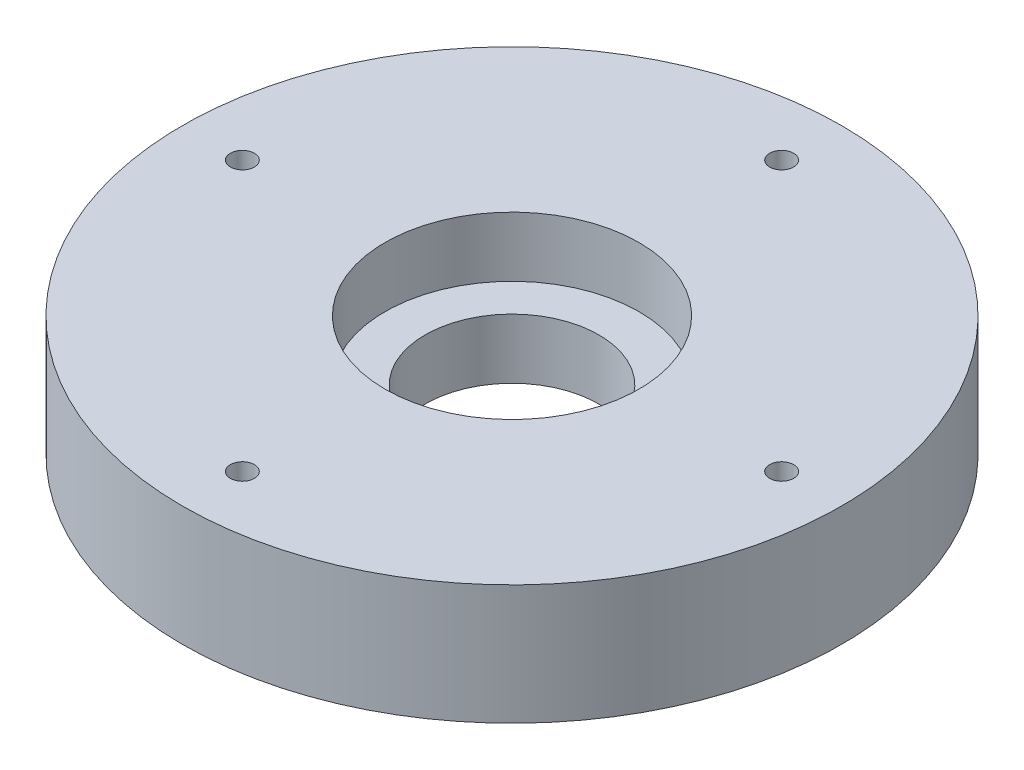
from build123d import *

# Parameters (mm, degrees)
SKETCH1_R           = 55
SKETCH1_R_2         = 14.5
BOSS_EXTRUDE1_DEPTH = 20
SKETCH2_R           = 21.2
CUT_EXTRUDE1_DEPTH  = 10
SKETCH4_R           = 2
CUT_EXTRUDE2_DEPTH  = 20
SKETCH6_R           = 5
CUT_EXTRUDE3_DEPTH  = 5


with BuildPart() as part:
    # Sketch1 → Boss-Extrude1 (new body)
    with BuildSketch(Plane(origin=(0, 0, 0), x_dir=(1, 0, 0), z_dir=(0, 1, 0))):
        Circle(SKETCH1_R)
        Circle(SKETCH1_R_2, mode=Mode.SUBTRACT)
    extrude(amount=BOSS_EXTRUDE1_DEPTH)

    # Sketch2 → Cut-Extrude1 (cut)
    with BuildSketch(Plane(origin=(0, 20, 0), x_dir=(1, 0, 0), z_dir=(0, 1, 0))):
        Circle(SKETCH2_R)
    extrude(amount=-CUT_EXTRUDE1_DEPTH, mode=Mode.SUBTRACT)

    # Sketch4 → Cut-Extrude2 (cut)
    with BuildSketch(Plane(origin=(0, 20, 0), x_dir=(1, 0, 0), z_dir=(0, 1, 0))):
        with Locations((0, 45)):
            Circle(SKETCH4_R)
        with Locations((45, 0)):
            Circle(SKETCH4_R)
        with Locations((0, -45)):
            Circle(SKETCH4_R)
        with Locations((-45, 0)):
            Circle(SKETCH4_R)
    extrude(amount=-CUT_EXTRUDE2_DEPTH, mode=Mode.SUBTRACT)

    # Sketch6 → Cut-Extrude3 (cut)
    with BuildSketch(Plane.XZ):
        with Locations((0, 45)):
            Circle(SKETCH6_R)
        with Locations((45, 0)):
            Circle(SKETCH6_R)
        with Locations((0, -45)):
            Circle(SKETCH6_R)
        with Locations((-45, 0)):
            Circle(SKETCH6_R)
    extrude(amount=-CUT_EXTRUDE3_DEPTH, mode=Mode.SUBTRACT)


solid = part.part
